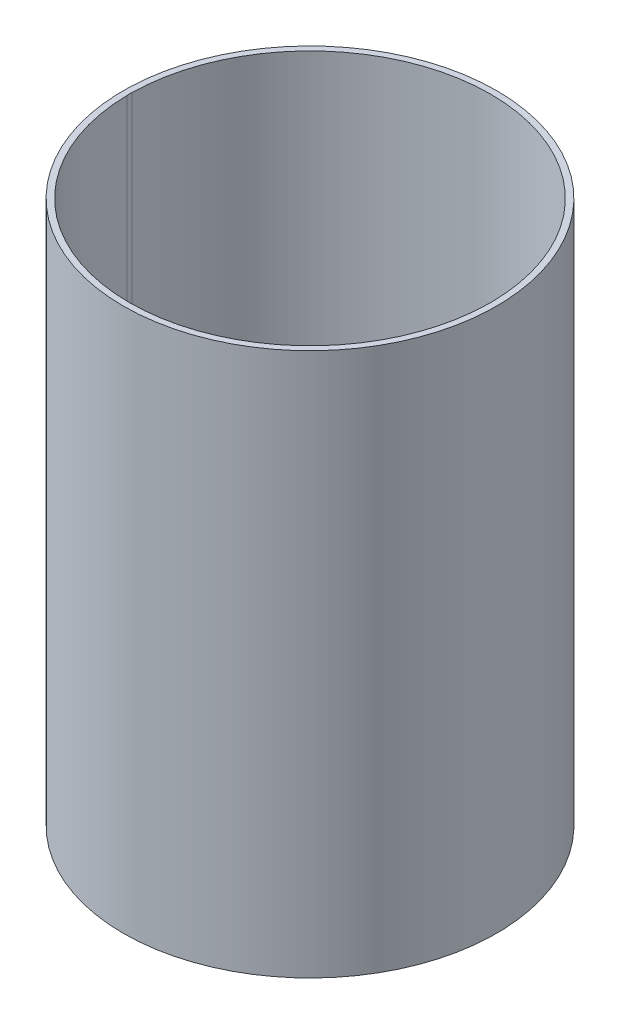
from build123d import *

# Parameters (mm, degrees)
SKETCH1_R           = 92.71
SKETCH1_R_2         = 53.975
BOSS_EXTRUDE1_DEPTH = 3.175
SKETCH2_R           = 92.71
SKETCH2_R_2         = 89.71
BOSS_EXTRUDE2_DEPTH = 266.7
SKETCH3_R           = 9.525
CUT_EXTRUDE1_DEPTH  = 270.875


with BuildPart() as part:
    # Sketch1 → Boss-Extrude1 (new body)
    with BuildSketch(Plane(origin=(0, 0, 0), x_dir=(1, 0, 0), z_dir=(0, 1, 0))):
        Circle(SKETCH1_R)
        Circle(SKETCH1_R_2, mode=Mode.SUBTRACT)
    extrude(amount=BOSS_EXTRUDE1_DEPTH)

    # Sketch2 → Boss-Extrude2 (add)
    with BuildSketch(Plane(origin=(0, 3.175, 0), x_dir=(1, 0, 0), z_dir=(0, 1, 0))):
        Circle(SKETCH2_R)
        Circle(SKETCH2_R_2, mode=Mode.SUBTRACT)
    extrude(amount=BOSS_EXTRUDE2_DEPTH)

    # Sketch3 → Cut-Extrude1 (cut, through all)
    with BuildSketch(Plane.XZ):
        with Locations((-80.264, 0)):
            Circle(SKETCH3_R)
        with Locations((80.264, 0)):
            Circle(SKETCH3_R)
    extrude(amount=-CUT_EXTRUDE1_DEPTH, mode=Mode.SUBTRACT)


solid = part.part
